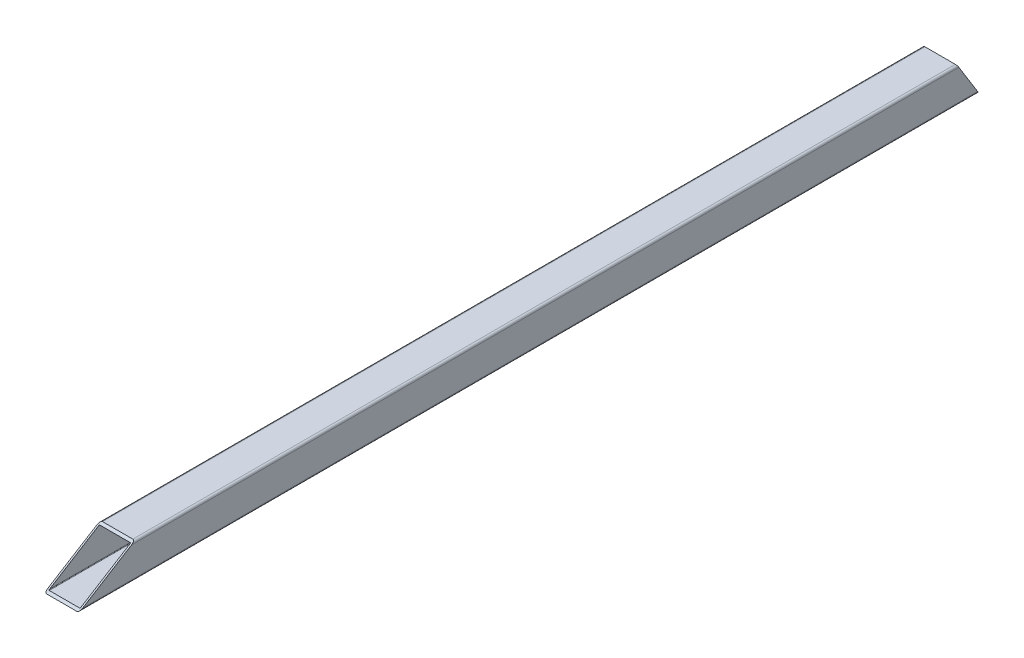
from build123d import *

# Parameters (mm, degrees)
BOSS_EXTRUDE1_DEPTH      = 415.2
BOSS_EXTRUDE1_DEPTH_BACK = 415.2
CUT_EXTRUDE1_DEPTH       = 417.738575128
CUT_EXTRUDE2_DEPTH       = 417.738575128


with BuildPart() as part:
    # Sketch1 → Boss-Extrude1 (new, two sides: drawn at the far end of the back side and taken through both)
    with BuildSketch(Plane.XY.offset(-BOSS_EXTRUDE1_DEPTH_BACK)):
        with BuildLine():
            Line((-14, -16), (14, -16))
            ThreePointArc((14, -16), (15.414213562, -15.414213562), (16, -14))
            Line((16, -14), (16, 14))
            ThreePointArc((16, 14), (15.414213562, 15.414213562), (14, 16))
            Line((14, 16), (-14, 16))
            ThreePointArc((-14, 16), (-15.414213562, 15.414213562), (-16, 14))
            Line((-16, 14), (-16, -14))
            ThreePointArc((-16, -14), (-15.414213562, -15.414213562), (-14, -16))
        make_face()
        with BuildLine():
            Line((-14, 14.48), (14, 14.48))
            ThreePointArc((14, 14.48), (14.339411255, 14.339411255), (14.48, 14))
            Line((14.48, 14), (14.48, -14))
            ThreePointArc((14.48, -14), (14.339411255, -14.339411255), (14, -14.48))
            Line((14, -14.48), (-14, -14.48))
            ThreePointArc((-14, -14.48), (-14.339411255, -14.339411255), (-14.48, -14))
            Line((-14.48, -14), (-14.48, 14))
            ThreePointArc((-14.48, 14), (-14.339411255, 14.339411255), (-14, 14.48))
        make_face(mode=Mode.SUBTRACT)
    extrude(amount=BOSS_EXTRUDE1_DEPTH + BOSS_EXTRUDE1_DEPTH_BACK)

    # Sketch2 → Cut-Extrude1 (cut, through all)
    with BuildSketch(Plane(origin=(16, 0, 0), x_dir=(0, 0, -1), z_dir=(1, 0, 0))):
        Polygon((-415.2, -16), (-415.2, 16), (-363.609390927, 16), align=None)
    extrude(amount=-CUT_EXTRUDE1_DEPTH, mode=Mode.SUBTRACT)

    # Sketch3 → Cut-Extrude2 (cut, through all)
    with BuildSketch(Plane(origin=(16, 0, 0), x_dir=(0, 0, -1), z_dir=(1, 0, 0))):
        Polygon((415.2, 16), (415.2, -16), (395.351426424, 16), align=None)
    extrude(amount=-CUT_EXTRUDE2_DEPTH, mode=Mode.SUBTRACT)


solid = part.part
